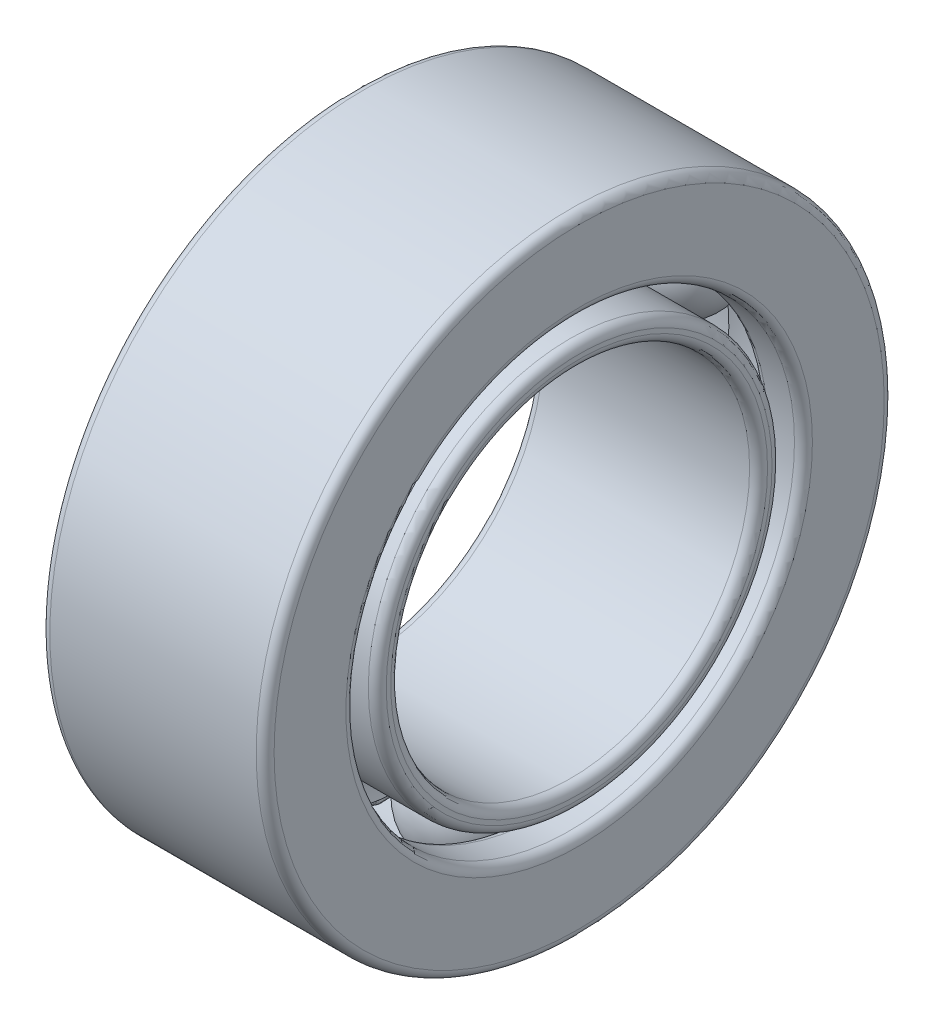
from build123d import *

# Parameters (mm, degrees)
SKETCH1_R             = 3.5
SKETCH1_R_2           = 3.25
BOSS_EXTRUDE1_DEPTH   = 1.25
SKETCH1_R_3           = 2.25
SKETCH1_R_4           = 2
BOSS_EXTRUDE1_2_DEPTH = 1.25
SKETCH7_W             = 0.5
SKETCH7_H             = 1
FILLET1_R             = 0.1
FILLET2_R             = 0.1
FILLET3_R             = 0.05


with BuildPart() as part:
    # Sketch1 → Boss-Extrude1 (new, symmetric)
    with BuildSketch(Plane(origin=(0, 0, 0), x_dir=(0, 0, -1), z_dir=(1, 0, 0))):
        Circle(SKETCH1_R)
        Circle(SKETCH1_R_2, mode=Mode.SUBTRACT)
    extrude(amount=BOSS_EXTRUDE1_DEPTH, both=True)


with BuildPart() as body_2:
    # Sketch1 → Boss-Extrude1 2 (new, symmetric)
    with BuildSketch(Plane(origin=(0, 0, 0), x_dir=(0, 0, -1), z_dir=(1, 0, 0))):
        Circle(SKETCH1_R_3)
        Circle(SKETCH1_R_4, mode=Mode.SUBTRACT)
    extrude(amount=BOSS_EXTRUDE1_2_DEPTH, both=True)


with BuildPart() as cut_revolve1_tool:
    # Sketch2 → Cut-Revolve1 (revolve)
    with BuildSketch(Plane.XY):
        with BuildLine():
            Line((0.331662479, 3.25), (-0.331662479, 3.25))
            ThreePointArc((-0.331662479, 3.25), (0, 3.35), (0.331662479, 3.25))
        make_face()
        with BuildLine():
            Line((0.331662479, 2.25), (-0.331662479, 2.25))
            ThreePointArc((-0.331662479, 2.25), (0, 2.15), (0.331662479, 2.25))
        make_face()
    revolve(axis=Axis((0, 0, 0), (1, 0, 0)))


with BuildPart() as part_1:
    add(part.part)

    # Cut-Revolve1: cut by cut_revolve1_tool
    add(cut_revolve1_tool.part, mode=Mode.SUBTRACT)

    # Sketch7 → Revolve5 (revolve)
    with BuildSketch(Plane.XY, mode=Mode.PRIVATE) as revolve5_sk:
        with Locations((1, 3)):
            Rectangle(SKETCH7_W, SKETCH7_H)
    revolve(revolve5_sk.sketch.rotate(Axis((0, 0, 0), (1, 0, 0)), 90), axis=Axis((0, 0, 0), (1, 0, 0)))

    # Fillet1
    fillet1_edges = [part_1.edges().sort_by_distance(p)[0] for p in [
        (0.75, 0, 3.25),
        (1.25, 0, -2.5),
        (0.75, 0, -2.5),
        (-1.25, 0, 3.5),
        (-1.25, 0, 3.25),
        (1.25, 0, 3.5),
    ]]
    fillet(fillet1_edges, radius=FILLET1_R)


with BuildPart() as body_2_1:
    add(body_2.part)

    # Cut-Revolve1: cut by cut_revolve1_tool
    add(cut_revolve1_tool.part, mode=Mode.SUBTRACT)

    # Fillet2
    fillet2_edges = [body_2_1.edges().sort_by_distance(p)[0] for p in [
        (-1.25, 0, 2.25),
        (-1.25, 0, 2),
        (1.25, 0, 2),
        (1.25, 0, 2.25),
    ]]
    fillet(fillet2_edges, radius=FILLET2_R)


with BuildPart() as body_3:
    # Sketch3 → Revolve1 (revolve)
    with BuildSketch(Plane(origin=(0, 0, 0), x_dir=(0, 0, -1), z_dir=(1, 0, 0))):
        with BuildLine():
            Line((0, 2.15), (0, 3.35))
            ThreePointArc((0, 3.35), (0.6, 2.75), (0, 2.15))
        make_face()
        with BuildLine():
            Line((0, -2.15), (0, -3.35))
            ThreePointArc((0, -3.35), (-0.6, -2.75), (0, -2.15))
        make_face()
    revolve(axis=Axis((0, 0, 0), (0, 1, 0)))


with BuildPart() as body_4:
    # Sketch4 → Revolve2 (revolve)
    with BuildSketch(Plane(origin=(0, 0, 0), x_dir=(0, 0, -1), z_dir=(1, 0, 0))):
        with BuildLine():
            Line((1.861954618, 1.075), (2.901185103, 1.675))
            ThreePointArc((2.901185103, 1.675), (2.68156986, 0.855384758), (1.861954618, 1.075))
        make_face()
        with BuildLine():
            Line((-1.861954618, -1.075), (-2.901185103, -1.675))
            ThreePointArc((-2.901185103, -1.675), (-2.68156986, -0.855384758), (-1.861954618, -1.075))
        make_face()
    revolve(axis=Axis((0, -1.075, 1.861954618), (0, -0.5000000000000012, 0.866025403784438)))


with BuildPart() as body_5:
    # Sketch5 → Revolve3 (revolve)
    with BuildSketch(Plane(origin=(0, 0, 0), x_dir=(0, 0, -1), z_dir=(1, 0, 0))):
        with BuildLine():
            Line((-2.38156986, 1.375), (-1.861954618, 1.075))
            ThreePointArc((-1.861954618, 1.075), (-2.08156986, 1.894615242), (-2.901185103, 1.675))
            Line((-2.901185103, 1.675), (-2.38156986, 1.375))
        make_face()
        with BuildLine():
            Line((2.38156986, -1.375), (1.861954618, -1.075))
            ThreePointArc((1.861954618, -1.075), (2.08156986, -1.894615242), (2.901185103, -1.675))
            Line((2.901185103, -1.675), (2.38156986, -1.375))
        make_face()
    revolve(axis=Axis((0, 1.075, 1.861954618), (0, 0.5000000000000012, 0.8660254037844379)))


with BuildPart() as body_6:
    # Sketch8 → Revolve6 (revolve)
    with BuildSketch(Plane.XY, mode=Mode.PRIVATE) as revolve6_sk:
        with BuildLine():
            Line((-1.15, 2.75), (-1.15, 3))
            Line((-1.15, 3), (-0.6, 3))
            ThreePointArc((-0.6, 3), (-0.65, 2.75), (-0.6, 2.5))
            Line((-0.6, 2.5), (-1.15, 2.5))
            Line((-1.15, 2.5), (-1.15, 2.75))
        make_face()
    revolve(revolve6_sk.sketch.rotate(Axis((0, 0, 0), (-1, 0, 0)), 270), axis=Axis((0, 0, 0), (-1, 0, 0)))

    # Fillet3
    fillet3_edges = [body_6.edges().sort_by_distance(p)[0] for p in [
        (-1.15, 0, -3),
        (-0.6, 0, -3),
        (-0.6, 0, -2.5),
        (-1.15, 0, -2.5),
    ]]
    fillet(fillet3_edges, radius=FILLET3_R)


solid = Compound([part_1.part, body_2_1.part, body_3.part, body_4.part, body_5.part, body_6.part])
